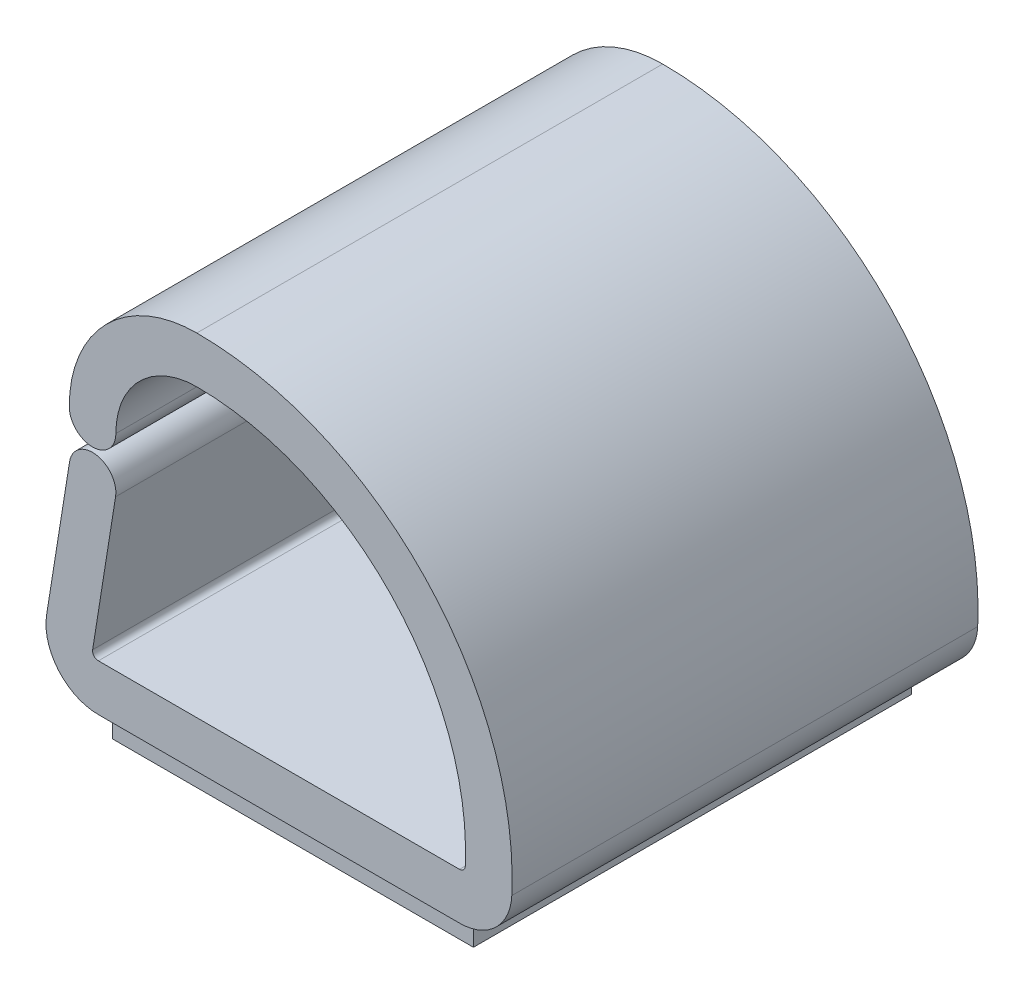
from build123d import *

# Parameters (mm, degrees)
BOSS_EXTRUDE3_DEPTH      = 6.35
BOSS_EXTRUDE3_DEPTH_BACK = 6.35
SKETCH6_W                = 9.8425
SKETCH6_H                = 11.938
BOSS_EXTRUDE4_DEPTH      = 0.762


with BuildPart() as part:
    # Sketch5 → Boss-Extrude3 (new body, two sides)
    with BuildSketch(Plane.XY) as boss_extrude3_sk:
        with BuildLine():
            Line((-4.92125, 0), (4.92125, 0))
            ThreePointArc((4.92125, 0), (5.908287619, 0.395752758), (6.348521584, 1.363770094))
            ThreePointArc((6.348521584, 1.363770094), (3.976448154, 7.693025011), (-2.238375, 10.3505))
            ThreePointArc((-2.238375, 10.3505), (-4.696720113, 9.332220113), (-5.715, 6.873875))
            ThreePointArc((-5.715, 6.873875), (-5.08, 6.238875), (-4.445, 6.873875))
            ThreePointArc((-4.445, 6.873875), (-3.798694501, 8.434194501), (-2.238375, 9.0805))
            ThreePointArc((-2.238375, 9.0805), (3.058228384, 6.815658238), (5.079835732, 1.42153001))
            ThreePointArc((5.079835732, 1.42153001), (5.030920847, 1.313972529), (4.92125, 1.27))
            Line((4.92125, 1.27), (-4.92125, 1.27))
            ThreePointArc((-4.92125, 1.27), (-5.042012288, 1.325706163), (-5.078022403, 1.453729514))
            Line((-5.078022403, 1.453729514), (-4.452910387, 5.376956946))
            ThreePointArc((-4.452910387, 5.376956946), (-4.980081946, 6.103964613), (-5.707089613, 5.576793054))
            Line((-5.707089613, 5.576793054), (-6.332201629, 1.653565622))
            ThreePointArc((-6.332201629, 1.653565622), (-6.00811059, 0.501355466), (-4.92125, 0))
        make_face()
    extrude(amount=BOSS_EXTRUDE3_DEPTH)
    extrude(boss_extrude3_sk.sketch, amount=-BOSS_EXTRUDE3_DEPTH_BACK)

    # Sketch6 → Boss-Extrude4 (add)
    with BuildSketch(Plane.XZ):
        Rectangle(SKETCH6_W, SKETCH6_H)
    extrude(amount=BOSS_EXTRUDE4_DEPTH)


solid = part.part
